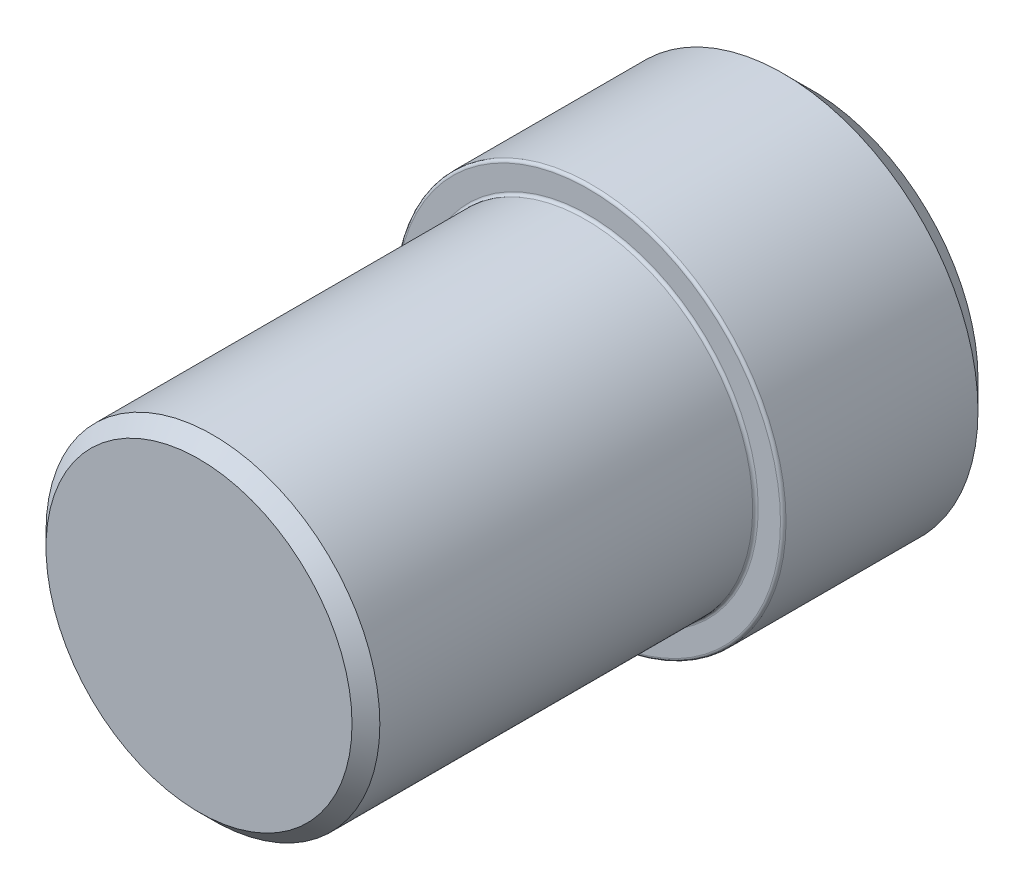
from build123d import *

# Parameters (mm, degrees)
SCHIZZO1_R                   = 3.5
ESTRUSIONE_ESTRUSIONE1_DEPTH = 4
SCHIZZO2_R                   = 3
ESTRUSIONE_ESTRUSIONE2_DEPTH = 7
SMUSSO1_SIZE                 = 0.25
SMUSSO2_SIZE                 = 0.5
RACCORDO1_R                  = 0.05


with BuildPart() as part:
    # Schizzo1 → Estrusione-Estrusione1 (new body)
    with BuildSketch(Plane.XY):
        Circle(SCHIZZO1_R)
    extrude(amount=ESTRUSIONE_ESTRUSIONE1_DEPTH)

    # Schizzo2 → Estrusione-Estrusione2 (add)
    with BuildSketch(Plane.XY.offset(4)):
        Circle(SCHIZZO2_R)
    extrude(amount=ESTRUSIONE_ESTRUSIONE2_DEPTH)

    # Smusso1
    smusso1_edges = [part.edges().sort_by_distance(p)[0] for p in [
        (-3, 0, 11),
    ]]
    chamfer(smusso1_edges, length=SMUSSO1_SIZE)

    # Smusso2
    smusso2_edges = [part.edges().sort_by_distance(p)[0] for p in [
        (-3.5, 0, 0),
    ]]
    chamfer(smusso2_edges, length=SMUSSO2_SIZE)

    # Raccordo1
    raccordo1_edges = [part.edges().sort_by_distance(p)[0] for p in [
        (-3.5, 0, 4),
        (-3, 0, 4),
    ]]
    fillet(raccordo1_edges, radius=RACCORDO1_R)


solid = part.part
